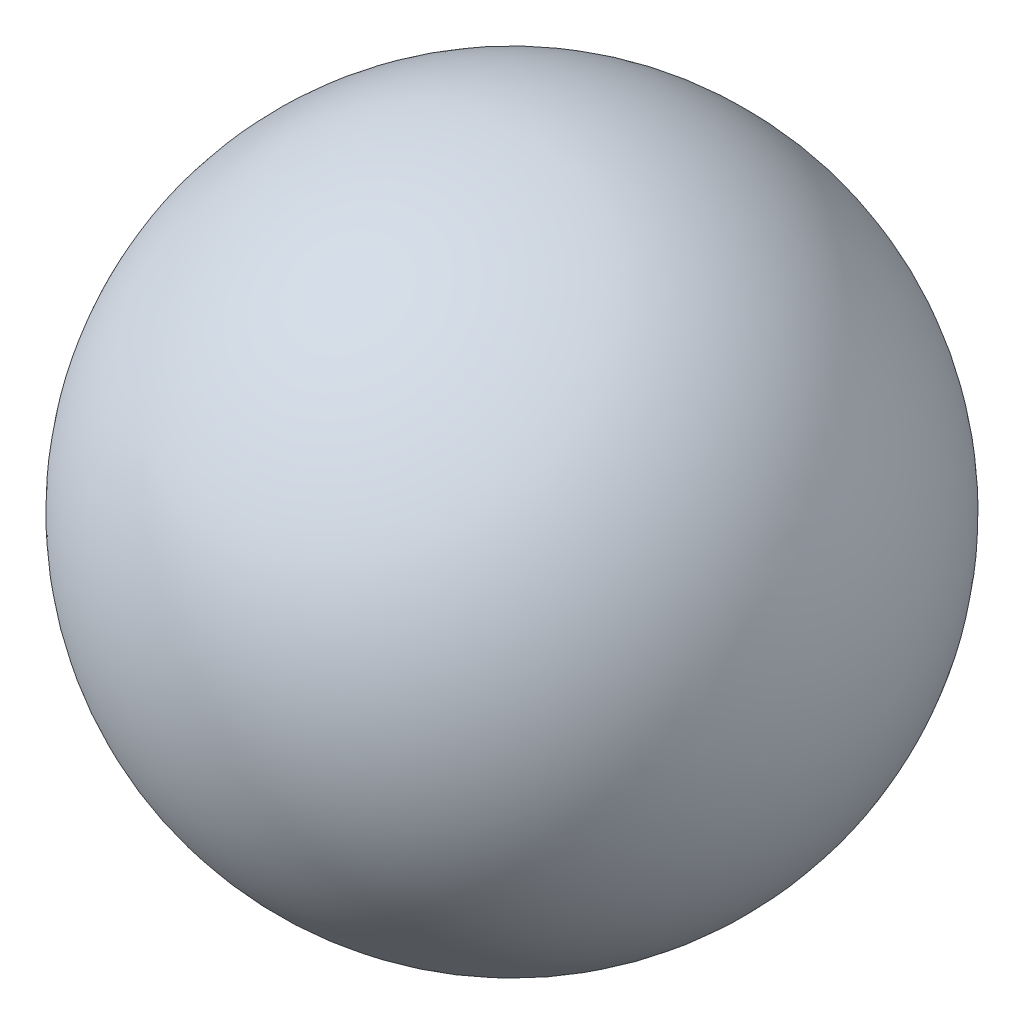
from build123d import *


with BuildPart() as part:
    # Croquis1 → Revolución1 (revolve)
    with BuildSketch(Plane.XY):
        with BuildLine():
            Line((3.969, 16.75), (-3.969, 16.75))
            ThreePointArc((-3.969, 16.75), (0, 20.719), (3.969, 16.75))
        make_face()
    revolve(axis=Axis((3.969, 16.75, 0), (-1, 0, 0)))


solid = part.part
